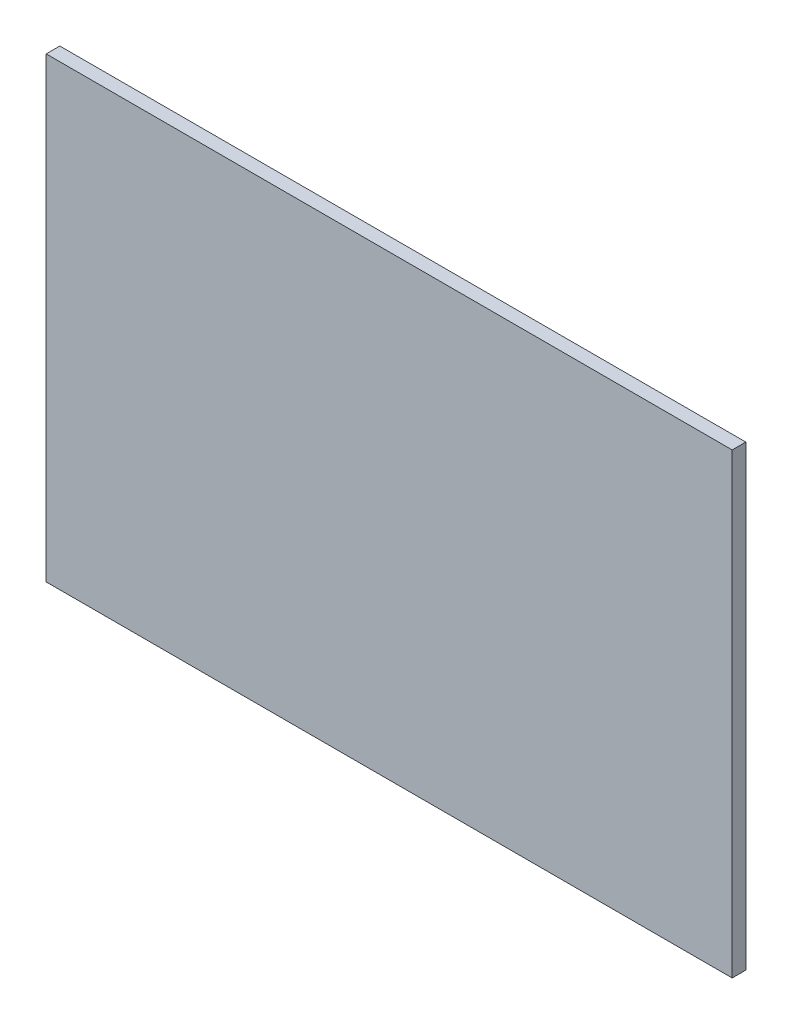
from build123d import *

# Parameters (mm, degrees)
SKETCH1_W           = 80.52
SKETCH1_H           = 53.68
BOSS_EXTRUDE1_DEPTH = 1.6


with BuildPart() as part:
    # Sketch1 → Boss-Extrude1 (new body)
    with BuildSketch(Plane.XY):
        Rectangle(SKETCH1_W, SKETCH1_H)
    extrude(amount=BOSS_EXTRUDE1_DEPTH)


solid = part.part
